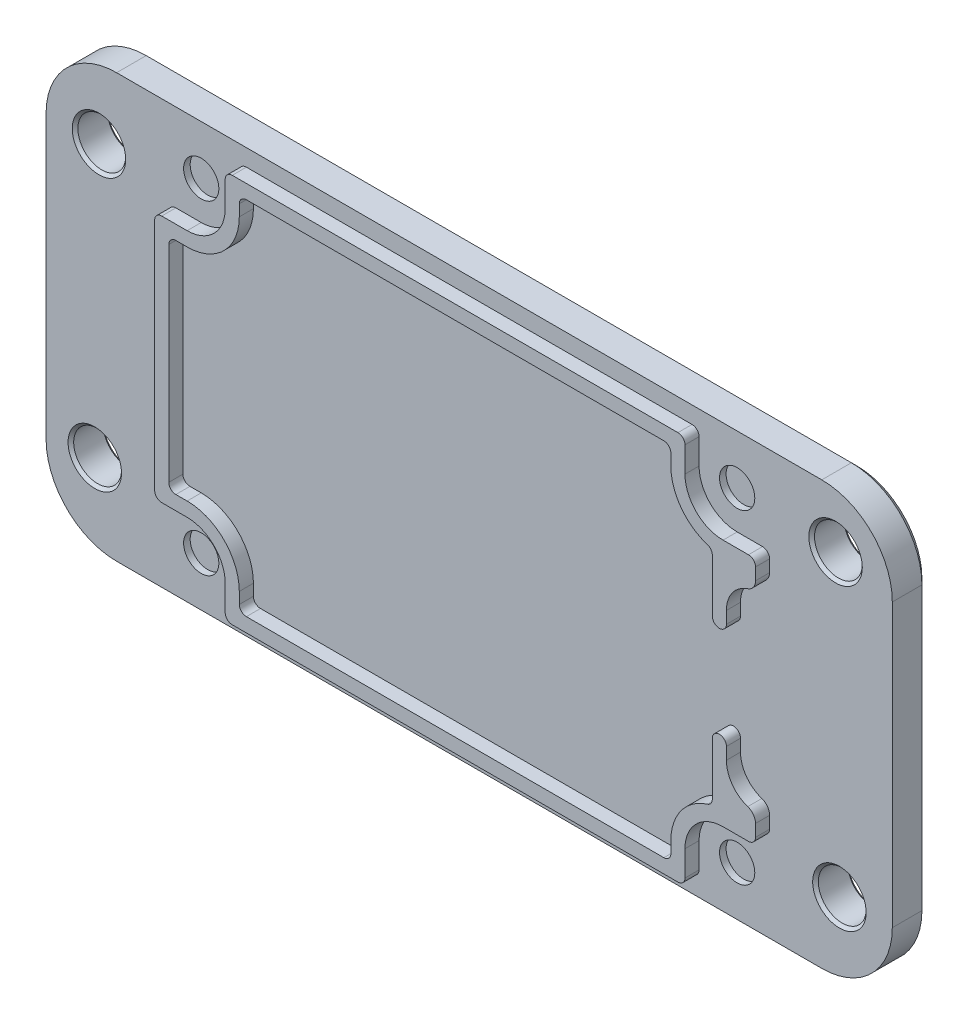
from build123d import *

# Parameters (mm, degrees)
SKETCH1_W                                    = 76.2
SKETCH1_H                                    = 38.1
BOSS_EXTRUDE1_DEPTH                          = 3.175
SKETCH4_R                                    = 1.5875
CUT_EXTRUDE1_DEPTH                           = 4.175
CBORE_FOR_2_PAN_HEAD_MACHINE_SCREW1_AT_COUNT = 2
CBORE_FOR_2_PAN_HEAD_MACHINE_SCREW1_AT_PITCH = 29.21
CBORE_FOR_2_PAN_HEAD_MACHINE_SCREW1_2_COUNT  = 2
CBORE_FOR_2_PAN_HEAD_MACHINE_SCREW1_2_PITCH  = 56.411450079
CBORE_FOR_2_PAN_HEAD_MACHINE_SCREW1_3_COUNT  = 2
CBORE_FOR_2_PAN_HEAD_MACHINE_SCREW1_3_PITCH  = 48.26
BOSS_EXTRUDE3_DEPTH                          = 1.27
FILLET1_R                                    = 6.35
FILLET2_R                                    = 0.635
FILLET3_R                                    = 0.635
F_6_CLEARANCE_HOLE1_D                        = 4.3053
CHAMFER1_SIZE                                = 0.508
CHAMFER2_SIZE                                = 0.254
CUT_EXTRUDE2_DEPTH                           = 2.27
SKETCH12_R                                   = 1.5875
BOSS_EXTRUDE4_DEPTH                          = 0.5


with BuildPart() as part:
    # Sketch1 → Boss-Extrude1 (new body)
    with BuildSketch(Plane.XY):
        Rectangle(SKETCH1_W, SKETCH1_H)
    extrude(amount=BOSS_EXTRUDE1_DEPTH)

    # Sketch4 → Cut-Extrude1 (cut, through all)
    with BuildSketch(Plane.XY.offset(3.175)):
        with Locations((24.13, -14.605)):
            Circle(SKETCH4_R)
        with Locations((24.13, 14.605)):
            Circle(SKETCH4_R)
        with Locations((-24.13, 14.605)):
            Circle(SKETCH4_R)
        with Locations((-24.13, -14.605)):
            Circle(SKETCH4_R)
    extrude(amount=-CUT_EXTRUDE1_DEPTH, mode=Mode.SUBTRACT)

    # Sketch7 → CBORE for #2 Pan Head Machine Screw1 (revolve, cut)
    with BuildSketch(Plane(origin=(24.13, 14.605, 0), x_dir=(0, 1, 0), z_dir=(1, 0, 0))):
        Polygon((0, 0), (0, 3.175), (1.35255, 3.175), (1.35255, 2.0828), (2.38125, 2.0828), (2.38125, 0.328717772), (2.667, 0), align=None)
    cbore_for_2_pan_head_machine_screw1 = revolve(axis=Axis((24.13, 14.605, -6.35), (0, 0, 1)), mode=Mode.SUBTRACT)

    # CBORE for #2 Pan Head Machine Screw1 at: CBORE for #2 Pan Head Machine Screw1 ×2
    with Locations(*[(0, -i * CBORE_FOR_2_PAN_HEAD_MACHINE_SCREW1_AT_PITCH, 0) for i in range(1, CBORE_FOR_2_PAN_HEAD_MACHINE_SCREW1_AT_COUNT)]):
        add(cbore_for_2_pan_head_machine_screw1, mode=Mode.SUBTRACT)

    # CBORE for _2 Pan Head Machine Screw1 2: CBORE for #2 Pan Head Machine Screw1 ×2
    with Locations(*[Vector(-0.855500079, -0.517802679, 0) * (i * CBORE_FOR_2_PAN_HEAD_MACHINE_SCREW1_2_PITCH) for i in range(1, CBORE_FOR_2_PAN_HEAD_MACHINE_SCREW1_2_COUNT)]):
        add(cbore_for_2_pan_head_machine_screw1, mode=Mode.SUBTRACT)

    # CBORE for _2 Pan Head Machine Screw1 3: CBORE for #2 Pan Head Machine Screw1 ×2
    with Locations(*[(-i * CBORE_FOR_2_PAN_HEAD_MACHINE_SCREW1_3_PITCH, 0, 0) for i in range(1, CBORE_FOR_2_PAN_HEAD_MACHINE_SCREW1_3_COUNT)]):
        add(cbore_for_2_pan_head_machine_screw1, mode=Mode.SUBTRACT)

    # Sketch5 → Boss-Extrude3 (add)
    with BuildSketch(Plane.XY.offset(3.175)):
        with BuildLine():
            ThreePointArc((-24.13, 11.176), (-21.705330847, 12.180330847), (-20.701, 14.605))
            Line((-20.701, 14.605), (-20.701, 17.526))
            Line((-20.701, 17.526), (20.701, 17.526))
            Line((20.701, 17.526), (20.701, 14.605))
            ThreePointArc((20.701, 14.605), (21.705330847, 12.180330847), (24.13, 11.176))
            Line((24.13, 11.176), (27.051, 11.176))
            Line((27.051, 11.176), (27.051, 9.461337048))
            ThreePointArc((27.051, 9.461337048), (26.858097964, 8.865714901), (26.35264224, 8.49626741))
            ThreePointArc((26.35264224, 8.49626741), (24.962639, 7.480286808), (24.4321584, 5.842325903))
            Line((24.4321584, 5.842325903), (24.4321584, -5.842325903))
            ThreePointArc((24.4321584, -5.842325903), (24.962639, -7.480286808), (26.35264224, -8.49626741))
            ThreePointArc((26.35264224, -8.49626741), (26.858097964, -8.865714901), (27.051, -9.461337048))
            Line((27.051, -9.461337048), (27.051, -11.176))
            Line((27.051, -11.176), (24.13, -11.176))
            ThreePointArc((24.13, -11.176), (21.705330847, -12.180330847), (20.701, -14.605))
            Line((20.701, -14.605), (20.701, -17.526))
            Line((20.701, -17.526), (-20.701, -17.526))
            Line((-20.701, -17.526), (-20.701, -14.605))
            ThreePointArc((-20.701, -14.605), (-21.705330847, -12.180330847), (-24.13, -11.176))
            Line((-24.13, -11.176), (-27.051, -11.176))
            Line((-27.051, -11.176), (-27.051, 11.176))
            Line((-27.051, 11.176), (-24.13, 11.176))
        make_face()
        with BuildLine():
            ThreePointArc((19.431, -14.605), (20.481131088, -11.644196619), (23.1621584, -10.006752112))
            Line((23.1621584, -10.006752112), (23.1621584, 10.006752112))
            ThreePointArc((23.1621584, 10.006752112), (20.481131088, 11.644196619), (19.431, 14.605))
            Line((19.431, 14.605), (19.431, 16.256))
            Line((19.431, 16.256), (-19.431, 16.256))
            Line((-19.431, 16.256), (-19.431, 14.605))
            ThreePointArc((-19.431, 14.605), (-20.807305235, 11.282305235), (-24.13, 9.906))
            Line((-24.13, 9.906), (-25.781, 9.906))
            Line((-25.781, 9.906), (-25.781, -9.906))
            Line((-25.781, -9.906), (-24.13, -9.906))
            ThreePointArc((-24.13, -9.906), (-20.807305235, -11.282305235), (-19.431, -14.605))
            Line((-19.431, -14.605), (-19.431, -16.256))
            Line((-19.431, -16.256), (19.431, -16.256))
            Line((19.431, -16.256), (19.431, -14.605))
        make_face(mode=Mode.SUBTRACT)
    extrude(amount=BOSS_EXTRUDE3_DEPTH)

    # Fillet1
    fillet1_edges = [part.edges().sort_by_distance(p)[0] for p in [
        (-38.1, 19.05, 1.5875),
        (38.1, 19.05, 1.5875),
        (38.1, -19.05, 1.5875),
        (-38.1, -19.05, 1.5875),
    ]]
    fillet(fillet1_edges, radius=FILLET1_R)

    # Fillet2
    fillet2_edges = [part.edges().sort_by_distance(p)[0] for p in [
        (-27.051, 11.176, 3.81),
        (-27.051, -11.176, 3.81),
        (-20.701, -17.526, 3.81),
        (20.701, -17.526, 3.81),
        (27.051, -11.176, 3.81),
        (27.051, 11.176, 3.81),
        (20.701, 17.526, 3.81),
        (-20.701, 17.526, 3.81),
    ]]
    fillet(fillet2_edges, radius=FILLET2_R)

    # Fillet3
    fillet3_edges = [part.edges().sort_by_distance(p)[0] for p in [
        (23.1621584, -10.006752112, 3.81),
        (19.431, -16.256, 3.81),
        (-19.431, -16.256, 3.81),
        (-25.781, -9.906, 3.81),
        (-25.781, 9.906, 3.81),
        (-19.431, 16.256, 3.81),
        (19.431, 16.256, 3.81),
        (23.1621584, 10.006752112, 3.81),
    ]]
    fillet(fillet3_edges, radius=FILLET3_R)

    # #6 Clearance Hole1 (through all)
    with Locations(Plane.XY.offset(3.175)):
        with Locations((-33.3375, 12.7), (-33.714363812, -11.954179128), (32.991908684, 14.039088205), (33.3375, -12.7)):
            Hole(F_6_CLEARANCE_HOLE1_D / 2)

    # Chamfer1
    chamfer1_edges = [part.edges().sort_by_distance(p)[0] for p in [
        (38.1, 0, 0),
        (-38.1, 0, 0),
        (0, 19.05, 0),
        (0, -19.05, 0),
        (-36.240128061, -17.190128061, 0),
        (-36.240128061, 17.190128061, 0),
        (36.240128061, 17.190128061, 0),
        (36.240128061, -17.190128061, 0),
    ]]
    chamfer(chamfer1_edges, length=CHAMFER1_SIZE)

    # Chamfer2
    chamfer2_edges = [part.edges().sort_by_distance(p)[0] for p in [
        (35.49015, -12.7, 3.175),
        (35.49015, -12.7, 0),
        (35.144558684, 14.039088205, 3.175),
        (35.144558684, 14.039088205, 0),
        (-31.561713812, -11.954179128, 3.175),
        (-31.561713812, -11.954179128, 0),
        (-31.18485, 12.7, 3.175),
        (-31.18485, 12.7, 0),
    ]]
    chamfer(chamfer2_edges, length=CHAMFER2_SIZE)

    # Sketch11 → Cut-Extrude2 (cut, through all)
    with BuildSketch(Plane.XY.offset(3.175)):
        with BuildLine():
            Line((24.4321584, 4.7625), (24.4321584, -4.7625))
            ThreePointArc((24.4321584, -4.7625), (23.7971584, -4.1275), (23.1621584, -4.7625))
            Line((23.1621584, -4.7625), (23.1621584, 4.7625))
            ThreePointArc((23.1621584, 4.7625), (23.7971584, 4.1275), (24.4321584, 4.7625))
        make_face()
    extrude(amount=CUT_EXTRUDE2_DEPTH, mode=Mode.SUBTRACT)

    # Sketch12 → Boss-Extrude4 (add)
    with BuildSketch(Plane(origin=(0, 0, 2.0828), x_dir=(-1, 0, 0), z_dir=(0, 0, -1))):
        with Locations((-24.13, 14.605)):
            Circle(SKETCH12_R)
        with Locations((24.13, 14.605)):
            Circle(SKETCH12_R)
        with Locations((24.13, -14.605)):
            Circle(SKETCH12_R)
        with Locations((-24.13, -14.605)):
            Circle(SKETCH12_R)
    extrude(amount=-BOSS_EXTRUDE4_DEPTH)


solid = part.part
